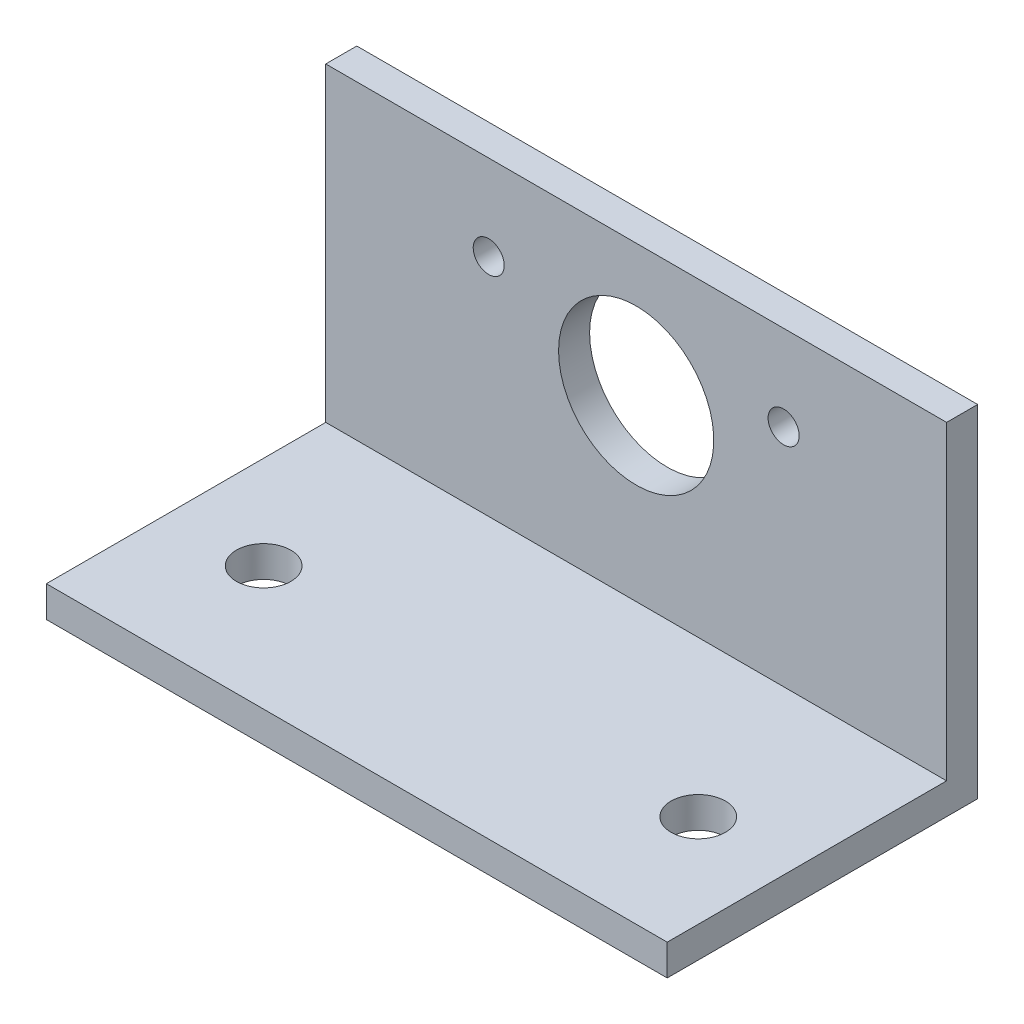
from build123d import *

# Parameters (mm, degrees)
SKETCH1_W           = 40
SKETCH1_H           = 20
BOSS_EXTRUDE1_DEPTH = 2
SKETCH2_W           = 40
SKETCH2_H           = 2
BOSS_EXTRUDE2_DEPTH = 20
SKETCH3_R           = 1.75
CUT_EXTRUDE1_DEPTH  = 23
SKETCH4_R           = 5
SKETCH4_R_2         = 1
CUT_EXTRUDE2_DEPTH  = 21


with BuildPart() as part:
    # Sketch1 → Boss-Extrude1 (new body)
    with BuildSketch(Plane(origin=(0, 0, 0), x_dir=(1, 0, 0), z_dir=(0, 1, 0))):
        Rectangle(SKETCH1_W, SKETCH1_H)
    extrude(amount=BOSS_EXTRUDE1_DEPTH)

    # Sketch2 → Boss-Extrude2 (add)
    with BuildSketch(Plane(origin=(0, 2, 0), x_dir=(1, 0, 0), z_dir=(0, 1, 0))):
        with Locations((0, 9)):
            Rectangle(SKETCH2_W, SKETCH2_H)
    extrude(amount=BOSS_EXTRUDE2_DEPTH)

    # Sketch3 → Cut-Extrude1 (cut, through all)
    with BuildSketch(Plane.XZ):
        with Locations((-14, 2)):
            Circle(SKETCH3_R)
        with Locations((14, 2)):
            Circle(SKETCH3_R)
    extrude(amount=-CUT_EXTRUDE1_DEPTH, mode=Mode.SUBTRACT)

    # Sketch4 → Cut-Extrude2 (cut, through all)
    with BuildSketch(Plane(origin=(0, 0, -10), x_dir=(-1, 0, 0), z_dir=(0, 0, -1))):
        with Locations((0, 13.5)):
            Circle(SKETCH4_R)
        with Locations((-9.5, 16.5)):
            Circle(SKETCH4_R_2)
        with Locations((9.5, 16.5)):
            Circle(SKETCH4_R_2)
    extrude(amount=-CUT_EXTRUDE2_DEPTH, mode=Mode.SUBTRACT)


solid = part.part
